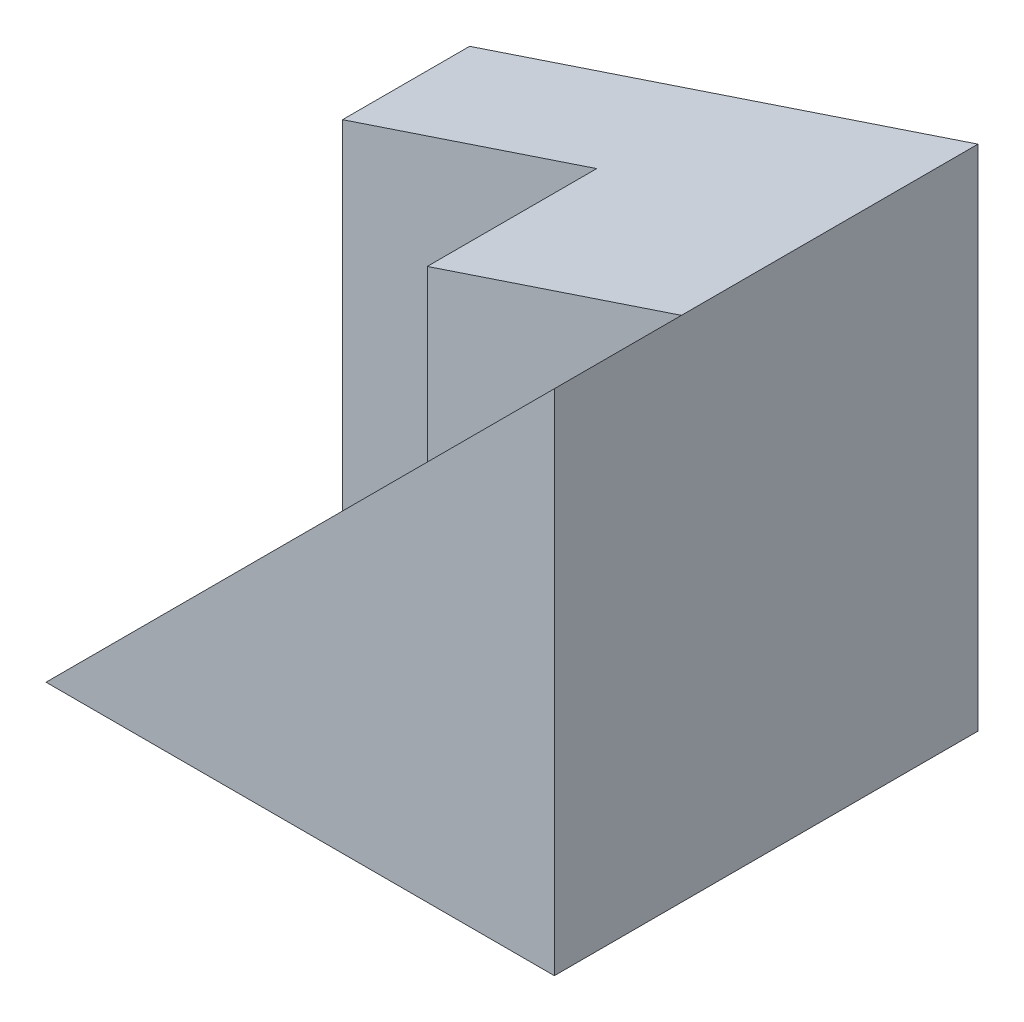
from build123d import *

# Parameters (mm, degrees)
SKETCH1_W           = 6
SKETCH1_H           = 5
BOSS_EXTRUDE1_DEPTH = 6
CUT_EXTRUDE1_DEPTH  = 3.5
SKETCH3_W           = 3
SKETCH3_H           = 2
BOSS_EXTRUDE2_DEPTH = 3
CUT_EXTRUDE2_DEPTH  = 3.5


with BuildPart() as part:
    # Sketch1 → Boss-Extrude1 (new body)
    with BuildSketch(Plane(origin=(0, 0, 0), x_dir=(1, 0, 0), z_dir=(0, 1, 0))):
        Rectangle(SKETCH1_W, SKETCH1_H)
    extrude(amount=BOSS_EXTRUDE1_DEPTH)

    # Sketch2 → Cut-Extrude1 (cut)
    with BuildSketch(Plane.XY.offset(2.5)):
        Polygon((3, 6), (-3, 0), (-3, 6), align=None)
    extrude(amount=-CUT_EXTRUDE1_DEPTH, mode=Mode.SUBTRACT)

    # Sketch3 → Boss-Extrude2 (add)
    with BuildSketch(Plane(origin=(0, 6, 0), x_dir=(1, 0, 0), z_dir=(0, 1, 0))):
        with Locations((1.5, 0)):
            Rectangle(SKETCH3_W, SKETCH3_H)
    extrude(amount=-BOSS_EXTRUDE2_DEPTH)

    # Sketch4 → Cut-Extrude2 (cut)
    with BuildSketch(Plane.XY.offset(1)):
        Polygon((3, 6), (-3, 4), (-3, 6), align=None)
    extrude(amount=-CUT_EXTRUDE2_DEPTH, mode=Mode.SUBTRACT)


solid = part.part
